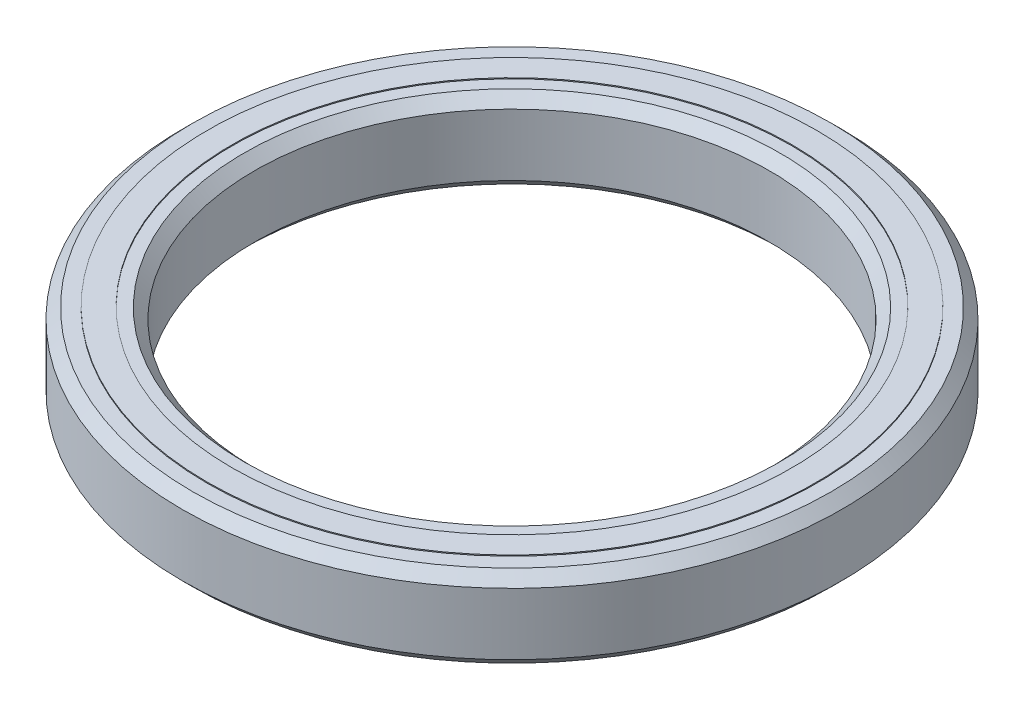
from build123d import *

# Parameters (mm, degrees)
CROQUIS1_R              = 16
CROQUIS1_R_2            = 12.5
SALIENTE_EXTRUIR1_DEPTH = 2
CHAFL_N1_SIZE           = 0.5
CROQUIS2_R              = 14.793460403
CROQUIS2_R_2            = 13.590473759
SALIENTE_EXTRUIR2_DEPTH = 2.05


with BuildPart() as part:
    # Croquis1 → Saliente-Extruir1 (new body, symmetric)
    with BuildSketch(Plane(origin=(0, 0, 0), x_dir=(1, 0, 0), z_dir=(0, 1, 0))):
        Circle(CROQUIS1_R)
        Circle(CROQUIS1_R_2, mode=Mode.SUBTRACT)
    extrude(amount=SALIENTE_EXTRUIR1_DEPTH, both=True)

    # Chaflán1
    chafl_n1_edges = [part.edges().sort_by_distance(p)[0] for p in [
        (-16, -2, 0),
        (-16, 2, 0),
        (-12.5, -2, 0),
        (-12.5, 2, 0),
    ]]
    chamfer(chafl_n1_edges, length=CHAFL_N1_SIZE)

    # Croquis2 → Saliente-Extruir2 (add, symmetric)
    with BuildSketch(Plane(origin=(0, 0, 0), x_dir=(1, 0, 0), z_dir=(0, 1, 0))):
        Circle(CROQUIS2_R)
        Circle(CROQUIS2_R_2, mode=Mode.SUBTRACT)
    extrude(amount=SALIENTE_EXTRUIR2_DEPTH, both=True)


solid = part.part
